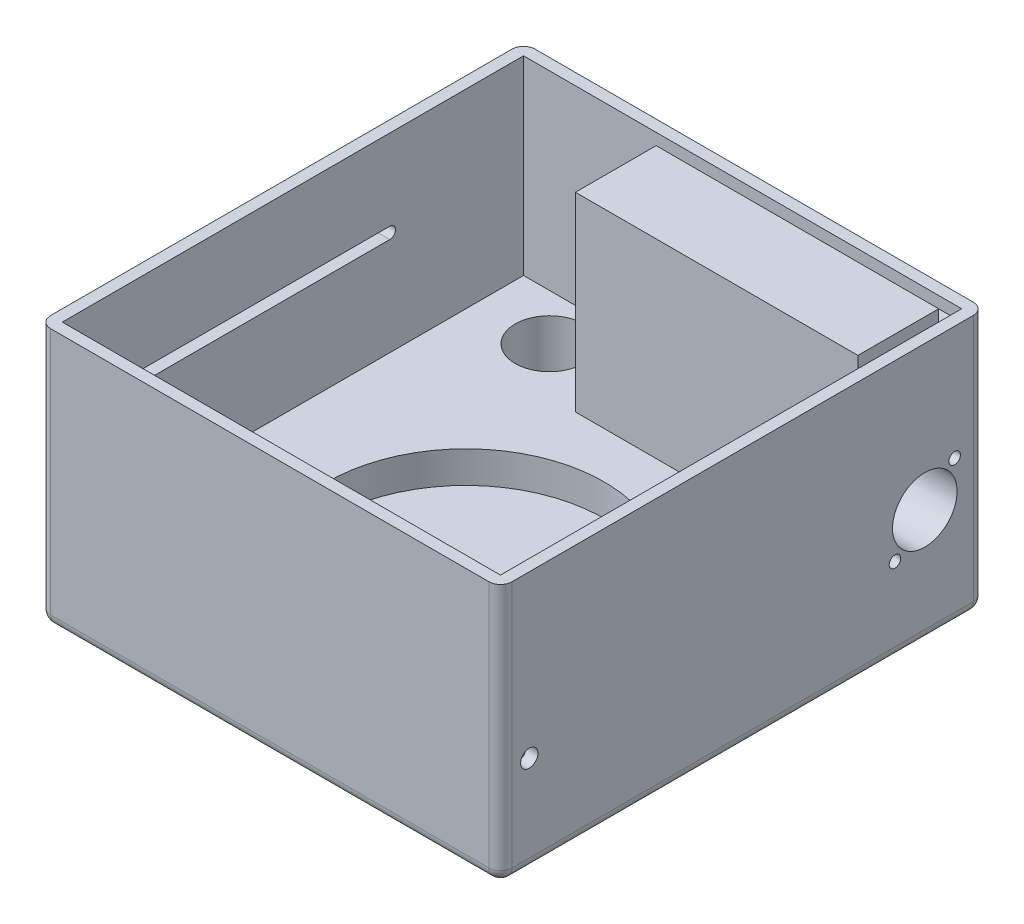
from build123d import *

# Parameters (mm, degrees)
SKETCH1_W           = 80
SKETCH1_H           = 68
BOSS_EXTRUDE1_DEPTH = 45
CUT_EXTRUDE1_START  = 45
SKETCH2_W           = 76
SKETCH2_H           = 64
CUT_EXTRUDE1_DEPTH  = 33
SKETCH6_R           = 10.5
CUT_EXTRUDE10_DEPTH = 5
SKETCH7_W           = 30
SKETCH7_H           = 30
SKETCH7_W_2         = 26
SKETCH7_H_2         = 26
CUT_EXTRUDE11_DEPTH = 2
SKETCH8_R           = 1.5
CUT_EXTRUDE12_DEPTH = 3
SKETCH5_R           = 5.95
CUT_EXTRUDE14_DEPTH = 46
FILLET1_R           = 0.5
CUT_EXTRUDE15_START = 12
SKETCH12_R          = 24
CUT_EXTRUDE15_DEPTH = 5.5
BOSS_EXTRUDE5_START = -34
SKETCH13_W          = 80
SKETCH13_H          = 45
BOSS_EXTRUDE5_DEPTH = 16
CUT_EXTRUDE16_START = 45
SKETCH15_W          = 25
SKETCH15_H          = 16
CUT_EXTRUDE16_DEPTH = 33
SKETCH16_R          = 5.95
CUT_EXTRUDE17_DEPTH = 10
CUT_EXTRUDE18_START = 40
SKETCH17_R          = 5.6
CUT_EXTRUDE18_DEPTH = 50
CUT_EXTRUDE19_START = 40
SKETCH20_R          = 1
CUT_EXTRUDE19_DEPTH = 53
FILLET3_R           = 2
FILLET4_R           = 2
CUT_EXTRUDE20_START = 45
SKETCH21_W          = 51
SKETCH21_H          = 2
CUT_EXTRUDE20_DEPTH = 2
CUT_EXTRUDE22_START = 45
SKETCH22_W          = 2
SKETCH22_H          = 14
CUT_EXTRUDE22_DEPTH = 2
CUT_EXTRUDE23_START = -40
CUT_EXTRUDE23_DEPTH = 2


with BuildPart() as part:
    # Sketch1 → Boss-Extrude1 (new body)
    with BuildSketch(Plane(origin=(0, 0, 0), x_dir=(1, 0, 0), z_dir=(0, 1, 0))):
        Rectangle(SKETCH1_W, SKETCH1_H)
    extrude(amount=BOSS_EXTRUDE1_DEPTH)

    # Sketch2 → Cut-Extrude1 (cut)
    with BuildSketch(Plane(origin=(0, 0, 0), x_dir=(1, 0, 0), z_dir=(0, 1, 0)).offset(CUT_EXTRUDE1_START)):
        Rectangle(SKETCH2_W, SKETCH2_H)
    extrude(amount=-CUT_EXTRUDE1_DEPTH, mode=Mode.SUBTRACT)

    # Sketch6 → Cut-Extrude10 (cut)
    with BuildSketch(Plane.XZ):
        Circle(SKETCH6_R)
    extrude(amount=-CUT_EXTRUDE10_DEPTH, mode=Mode.SUBTRACT)

    # Sketch7 → Cut-Extrude11 (cut)
    with BuildSketch(Plane(origin=(0, 0, 0), x_dir=(-1, 0, 0), z_dir=(0, -1, 0))):
        Rectangle(SKETCH7_W, SKETCH7_H)
        Rectangle(SKETCH7_W_2, SKETCH7_H_2, mode=Mode.SUBTRACT)
    extrude(amount=-CUT_EXTRUDE11_DEPTH, mode=Mode.SUBTRACT)

    # Sketch8 → Cut-Extrude12 (cut, through all)
    with BuildSketch(Plane.ZY.offset(-38)):
        with Locations((29, 17)):
            Circle(SKETCH8_R)
    extrude(amount=-CUT_EXTRUDE12_DEPTH, mode=Mode.SUBTRACT)

    # Sketch5 → Cut-Extrude14 (cut, through all)
    with BuildSketch(Plane(origin=(0, 0, 0), x_dir=(1, 0, 0), z_dir=(0, 1, 0))):
        Circle(SKETCH5_R)
    extrude(amount=CUT_EXTRUDE14_DEPTH, mode=Mode.SUBTRACT)

    # Fillet1
    fillet1_edges = [part.edges().sort_by_distance(p)[0] for p in [
        (15, 0, 0),
        (0, 0, 15),
        (-15, 0, 0),
        (0, 0, -15),
        (13, 0, 0),
        (0, 0, -13),
        (-13, 0, 0),
        (0, 0, 13),
    ]]
    fillet(fillet1_edges, radius=FILLET1_R)

    # Sketch12 → Cut-Extrude15 (cut)
    with BuildSketch(Plane(origin=(0, 0, 0), x_dir=(1, 0, 0), z_dir=(0, 1, 0)).offset(CUT_EXTRUDE15_START)):
        Circle(SKETCH12_R)
    extrude(amount=-CUT_EXTRUDE15_DEPTH, mode=Mode.SUBTRACT)

    # Sketch13 → Boss-Extrude5 (add)
    with BuildSketch(Plane.XY.offset(BOSS_EXTRUDE5_START)):
        with Locations((0, 22.5)):
            Rectangle(SKETCH13_W, SKETCH13_H)
    extrude(amount=-BOSS_EXTRUDE5_DEPTH)

    # Sketch15 → Cut-Extrude16 (cut)
    with BuildSketch(Plane(origin=(0, 0, 0), x_dir=(1, 0, 0), z_dir=(0, 1, 0)).offset(CUT_EXTRUDE16_START)):
        with Locations((-25.5, 40)):
            Rectangle(SKETCH15_W, SKETCH15_H)
    extrude(amount=-CUT_EXTRUDE16_DEPTH, mode=Mode.SUBTRACT)

    # Sketch16 → Cut-Extrude17 (cut)
    with BuildSketch(Plane(origin=(0, 12, 0), x_dir=(1, 0, 0), z_dir=(0, 1, 0))):
        with Locations((-25.5, 40)):
            Circle(SKETCH16_R)
    extrude(amount=-CUT_EXTRUDE17_DEPTH, mode=Mode.SUBTRACT)

    # Sketch17 → Cut-Extrude18 (cut)
    with BuildSketch(Plane(origin=(0, 0, 0), x_dir=(0, 0, -1), z_dir=(1, 0, 0)).offset(CUT_EXTRUDE18_START)):
        with Locations((39.6, 20.00233054)):
            Circle(SKETCH17_R)
    extrude(amount=-CUT_EXTRUDE18_DEPTH, mode=Mode.SUBTRACT)

    # Sketch20 → Cut-Extrude19 (cut)
    with BuildSketch(Plane(origin=(0, 0, 0), x_dir=(0, 0, -1), z_dir=(1, 0, 0)).offset(CUT_EXTRUDE19_START)):
        with Locations((44.775, 25.17733054)):
            Circle(SKETCH20_R)
        with Locations((34.425, 14.82733054)):
            Circle(SKETCH20_R)
    extrude(amount=-CUT_EXTRUDE19_DEPTH, mode=Mode.SUBTRACT)

    # Fillet3
    fillet3_edges = [part.edges().sort_by_distance(p)[0] for p in [
        (-40, 22.5, -50),
        (40, 22.5, 34),
        (-40, 22.5, 34),
        (40, 22.5, -50),
    ]]
    fillet(fillet3_edges, radius=FILLET3_R)

    # Fillet4
    fillet4_edges = [part.edges().sort_by_distance(p)[0] for p in [
        (40, 0, -8),
        (0, 0, 34),
        (-40, 0, -8),
        (0, 0, -50),
        (-39.414213562, 0, 33.414213562),
        (-39.414213562, 0, -49.414213562),
        (39.414213562, 0, -49.414213562),
        (39.414213562, 0, 33.414213562),
    ]]
    fillet(fillet4_edges, radius=FILLET4_R)

    # Sketch21 → Cut-Extrude20 (cut)
    with BuildSketch(Plane(origin=(0, 0, 0), x_dir=(1, 0, 0), z_dir=(0, 1, 0)).offset(CUT_EXTRUDE20_START)):
        with Locations((12.5, 47)):
            Rectangle(SKETCH21_W, SKETCH21_H)
    extrude(amount=-CUT_EXTRUDE20_DEPTH, mode=Mode.SUBTRACT)

    # Sketch22 → Cut-Extrude22 (cut)
    with BuildSketch(Plane(origin=(0, 0, 0), x_dir=(1, 0, 0), z_dir=(0, 1, 0)).offset(CUT_EXTRUDE22_START)):
        with Locations((37, 39)):
            Rectangle(SKETCH22_W, SKETCH22_H)
    extrude(amount=-CUT_EXTRUDE22_DEPTH, mode=Mode.SUBTRACT)

    # Sketch23 → Cut-Extrude23 (cut)
    with BuildSketch(Plane(origin=(0, 0, 0), x_dir=(0, 0, -1), z_dir=(1, 0, 0)).offset(CUT_EXTRUDE23_START)):
        with BuildLine():
            Line((-20.205872853, 31), (24.794127147, 31))
            ThreePointArc((24.794127147, 31), (25.794127147, 30), (24.794127147, 29))
            Line((24.794127147, 29), (-20.205872853, 29))
            ThreePointArc((-20.205872853, 29), (-21.205872853, 30), (-20.205872853, 31))
        make_face()
    extrude(amount=CUT_EXTRUDE23_DEPTH, mode=Mode.SUBTRACT)


solid = part.part
